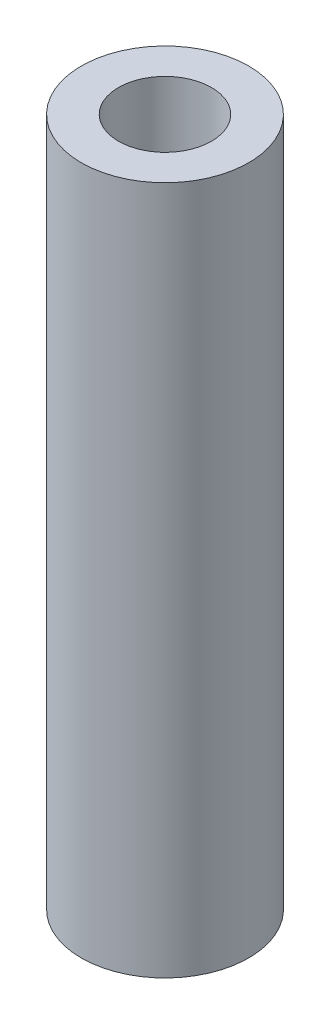
from build123d import *

# Parameters (mm, degrees)
SKETCH1_R                = 4.5
SKETCH1_R_2              = 2.5
BOSS_EXTRUDE1_DEPTH      = 0.5
SKETCH1_2_R              = 4.5
SKETCH1_2_R_2            = 2.5
BOSS_EXTRUDE2_DEPTH      = 18.5
BOSS_EXTRUDE2_DEPTH_BACK = 18.5


with BuildPart() as part:
    # Sketch1 → Boss-Extrude1 (new body, symmetric)
    with BuildSketch(Plane(origin=(0, 0, 0), x_dir=(1, 0, 0), z_dir=(0, 1, 0))):
        Circle(SKETCH1_R)
        Circle(SKETCH1_R_2, mode=Mode.SUBTRACT)
    extrude(amount=BOSS_EXTRUDE1_DEPTH, both=True)

    # Sketch1_2 → Boss-Extrude2 (add, two sides)
    with BuildSketch(Plane(origin=(0, 0, 0), x_dir=(1, 0, 0), z_dir=(0, 1, 0))) as boss_extrude2_sk:
        Circle(SKETCH1_2_R)
        Circle(SKETCH1_2_R_2, mode=Mode.SUBTRACT)
    extrude(amount=BOSS_EXTRUDE2_DEPTH)
    extrude(boss_extrude2_sk.sketch, amount=-BOSS_EXTRUDE2_DEPTH_BACK)


solid = part.part
